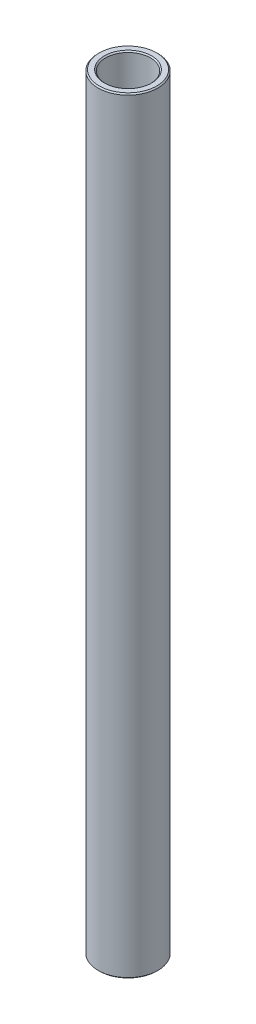
from build123d import *

# Parameters (mm, degrees)
SKETCH1_W     = 1.5875
SKETCH1_H     = 162.848779076
CHAMFER1_SIZE = 0.254


with BuildPart() as part:
    # Sketch1 → Revolve1 (revolve)
    with BuildSketch(Plane.XY):
        with Locations((5.55625, 90.949389538)):
            Rectangle(SKETCH1_W, SKETCH1_H)
    revolve(axis=Axis((0, 0, 0), (0, 1, 0)))

    # Chamfer1
    chamfer1_edges = [part.edges().sort_by_distance(p)[0] for p in [
        (-6.35, 9.525, 0),
        (-6.349999999, 172.373779076, 0),
        (-4.762499999, 172.373779076, 0),
        (-4.7625, 9.525, 0),
    ]]
    chamfer(chamfer1_edges, length=CHAMFER1_SIZE)


solid = part.part
